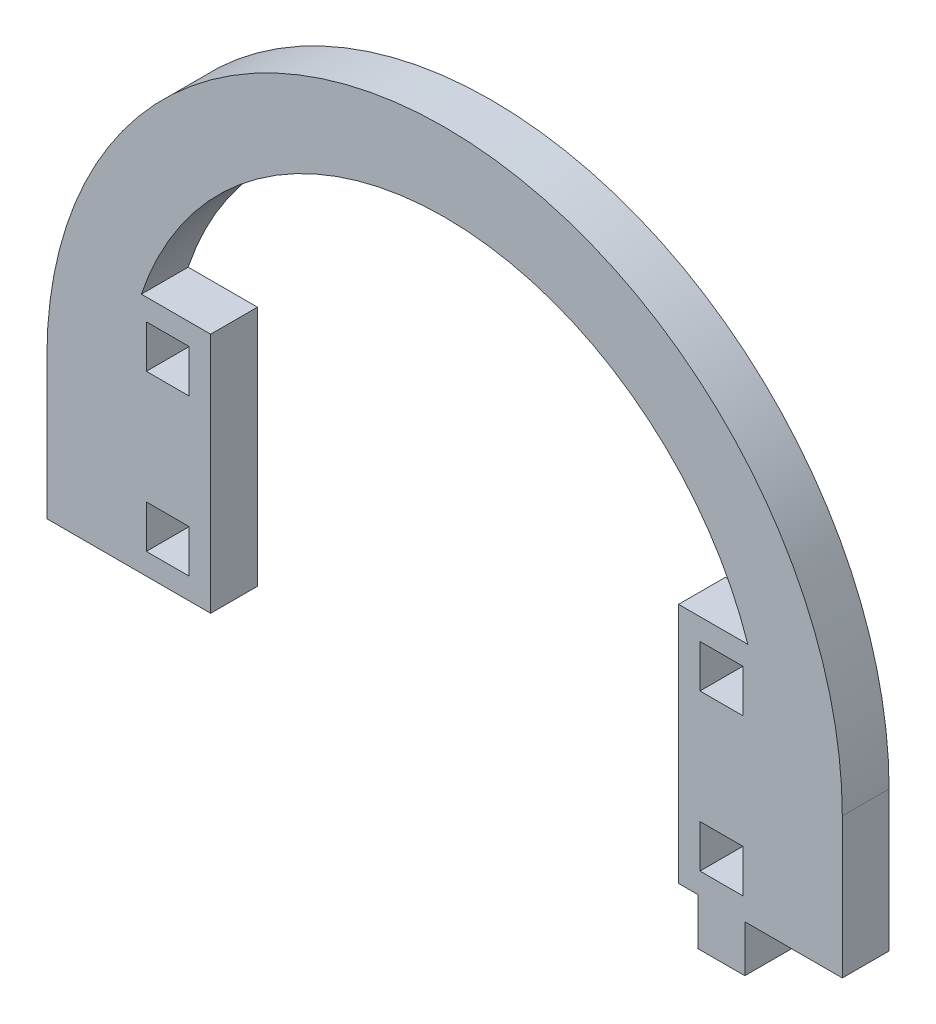
from build123d import *

# Parameters (mm, degrees)
MODEL_W             = 5.5
MODEL_H             = 5.5
BOSS_EXTRUDE1_DEPTH = 6


with BuildPart() as part:
    # Model → Boss-Extrude1 (new body)
    with BuildSketch(Plane.XY):
        with BuildLine():
            Line((3030.370462186, 1416.788914981), (3030.370462186, 1398.788914981))
            Line((3030.370462186, 1398.788914981), (3040.370462186, 1398.788914981))
            Line((3040.370462186, 1398.788914981), (3051.370462186, 1398.788914981))
            Line((3051.370462186, 1398.788914981), (3051.370462186, 1429.788914981))
            Line((3051.370462186, 1429.788914981), (3042.486017996, 1429.788914981))
            ThreePointArc((3042.486017996, 1429.788914981), (3081.370462186, 1457.788914981), (3120.254906376, 1429.788914981))
            Line((3120.254906376, 1429.788914981), (3111.370462186, 1429.788914981))
            Line((3111.370462186, 1429.788914981), (3111.370462186, 1398.788914981))
            Line((3111.370462186, 1398.788914981), (3113.870462186, 1398.788914981))
            Line((3113.870462186, 1398.788914981), (3113.870462186, 1392.788914981))
            Line((3113.870462186, 1392.788914981), (3119.870462186, 1392.788914981))
            Line((3119.870462186, 1392.788914981), (3119.870462186, 1398.788914981))
            Line((3119.870462186, 1398.788914981), (3132.370462186, 1398.788914981))
            Line((3132.370462186, 1398.788914981), (3132.370462186, 1416.788914981))
            ThreePointArc((3132.370462186, 1416.788914981), (3081.370462186, 1467.788914981), (3030.370462186, 1416.788914981))
        make_face()
        with Locations((3116.870462186, 1404.288914981)):
            Rectangle(MODEL_W, MODEL_H, mode=Mode.SUBTRACT)
        with Locations((3116.870462186, 1424.288914981)):
            Rectangle(MODEL_W, MODEL_H, mode=Mode.SUBTRACT)
        with Locations((3045.870462186, 1404.288914981)):
            Rectangle(MODEL_W, MODEL_H, mode=Mode.SUBTRACT)
        with Locations((3045.870462186, 1424.288914981)):
            Rectangle(MODEL_W, MODEL_H, mode=Mode.SUBTRACT)
    extrude(amount=BOSS_EXTRUDE1_DEPTH)


solid = part.part
